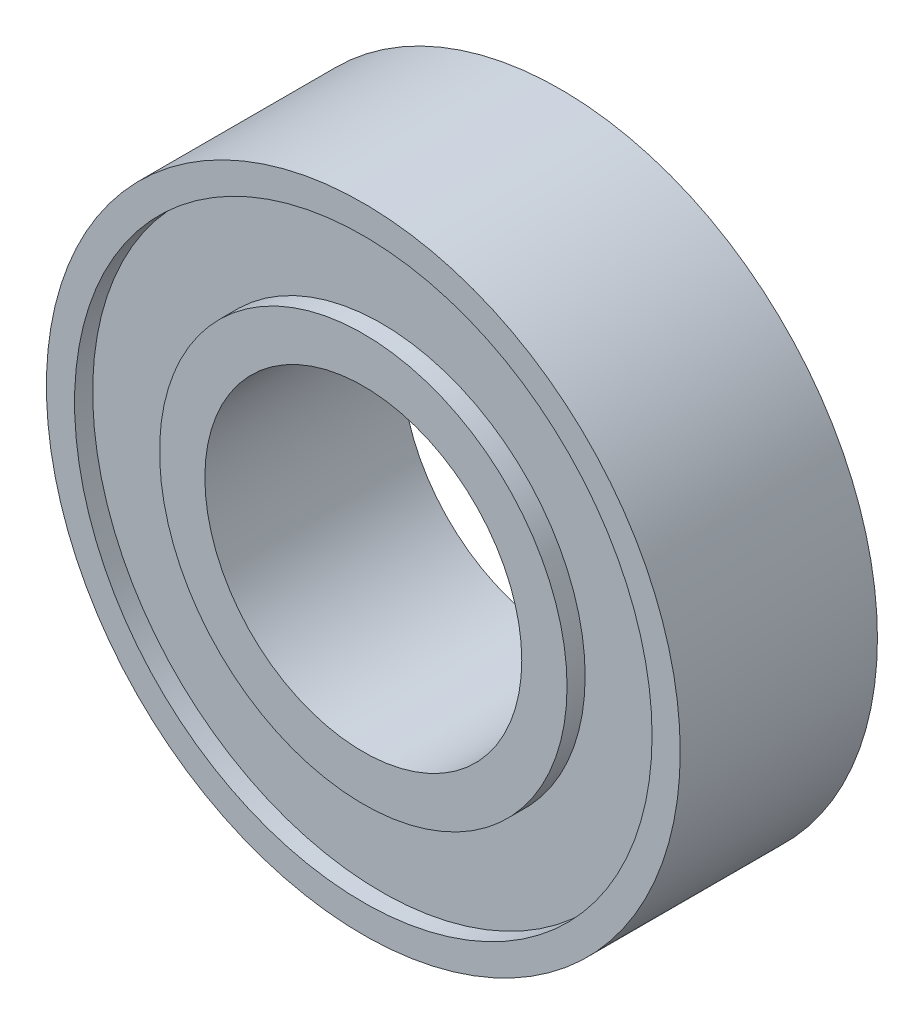
from build123d import *

# Parameters (mm, degrees)
SKETCH1_R           = 8.001
SKETCH1_R_2         = 4.0005
BOSS_EXTRUDE1_DEPTH = 4.9784
SKETCH2_R           = 7.2898
SKETCH2_R_2         = 5.1435
CUT_EXTRUDE1_DEPTH  = 0.4572
CUT_EXTRUDE2_START  = -0.4572
SKETCH3_R           = 7.2898
SKETCH3_R_2         = 5.1435
CUT_EXTRUDE2_DEPTH  = 0.4572


with BuildPart() as part:
    # Sketch1 → Boss-Extrude1 (new body)
    with BuildSketch(Plane.XY):
        Circle(SKETCH1_R)
        Circle(SKETCH1_R_2, mode=Mode.SUBTRACT)
    extrude(amount=BOSS_EXTRUDE1_DEPTH)

    # Sketch2 → Cut-Extrude1 (cut)
    with BuildSketch(Plane.XY.offset(4.9784)):
        Circle(SKETCH2_R)
        Circle(SKETCH2_R_2, mode=Mode.SUBTRACT)
    extrude(amount=-CUT_EXTRUDE1_DEPTH, mode=Mode.SUBTRACT)

    # Sketch3 → Cut-Extrude2 (cut)
    with BuildSketch(Plane(origin=(0, 0, 0), x_dir=(-1, 0, 0), z_dir=(0, 0, -1)).offset(CUT_EXTRUDE2_START)):
        Circle(SKETCH3_R)
        Circle(SKETCH3_R_2, mode=Mode.SUBTRACT)
    extrude(amount=CUT_EXTRUDE2_DEPTH, mode=Mode.SUBTRACT)


solid = part.part
